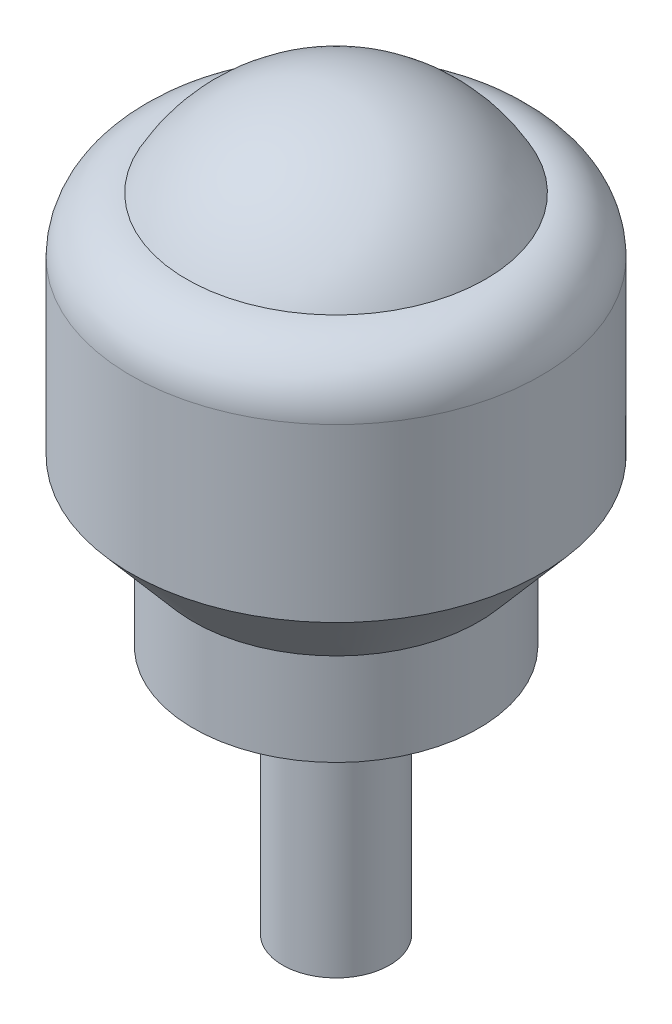
from build123d import *


with BuildPart() as part:
    # Esquisse1 → Révolution1 (revolve)
    with BuildSketch(Plane.XY):
        with BuildLine():
            Line((11.5, 1.406527307), (11.5, -8.206711775))
            Line((11.5, -8.206711775), (8, -12.301381653))
            Line((8, -12.301381653), (8, -17.475))
            Line((8, -17.475), (3, -17.475))
            Line((3, -17.475), (3, -31.475))
            Line((3, -31.475), (0, -31.475))
            Line((0, -31.475), (0, 9.525))
            ThreePointArc((0, 9.525), (4.879805324, 8.180044315), (8.381527307, 4.525))
            ThreePointArc((8.381527307, 4.525), (10.586620495, 3.611620495), (11.5, 1.406527307))
        make_face()
    revolve(axis=Axis((0, 9.525, 0), (0, -1, 0)))


solid = part.part
